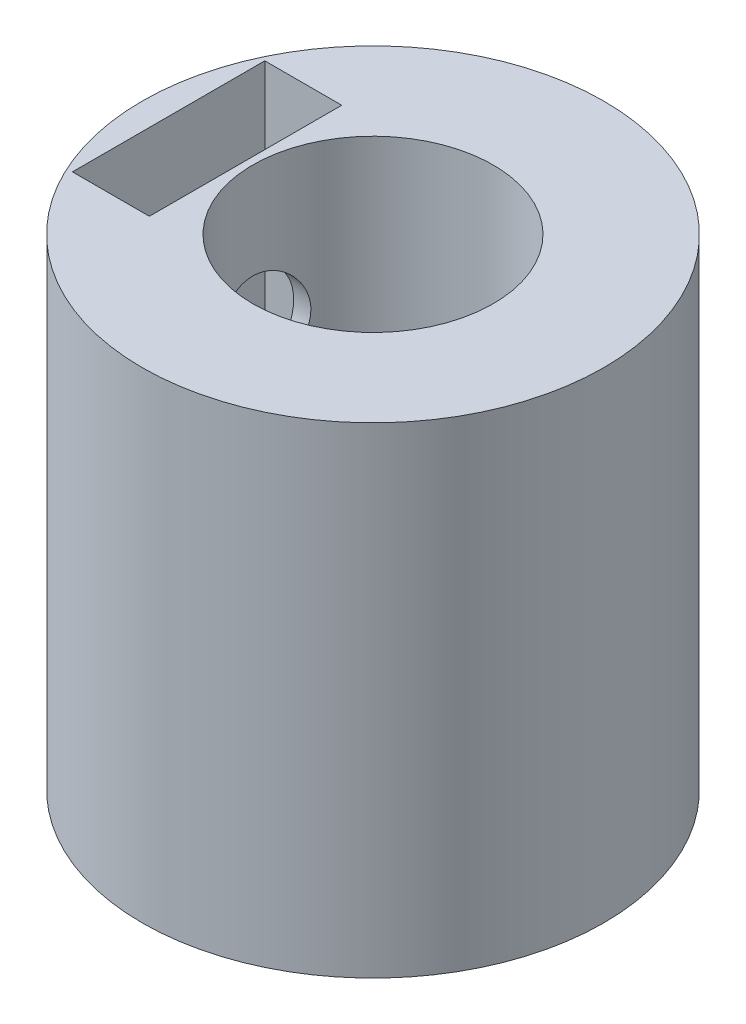
from build123d import *

# Parameters (mm, degrees)
IZIM1_R                     = 4.8
Y_KSEKLIK_EKSTR_ZYON1_DEPTH = 10
IZIM2_R                     = 2.5
KES_EKSTR_ZYON1_DEPTH       = 7
IZIM3_R                     = 1
KES_EKSTR_ZYON2_DEPTH       = 5.8
IZIM4_W                     = 1.6
IZIM4_H                     = 4
KES_EKSTR_ZYON3_DEPTH       = 5


with BuildPart() as part:
    # Çizim1 → Yükseklik-Ekstrüzyon1 (new body)
    with BuildSketch(Plane(origin=(0, 0, 0), x_dir=(1, 0, 0), z_dir=(0, 1, 0))):
        Circle(IZIM1_R)
    extrude(amount=Y_KSEKLIK_EKSTR_ZYON1_DEPTH)

    # Çizim2 → Kes-Ekstrüzyon1 (cut)
    with BuildSketch(Plane(origin=(0, 10, 0), x_dir=(1, 0, 0), z_dir=(0, 1, 0))):
        Circle(IZIM2_R)
    extrude(amount=-KES_EKSTR_ZYON1_DEPTH, mode=Mode.SUBTRACT)

    # Çizim3 → Kes-Ekstrüzyon2 (cut, through all)
    with BuildSketch(Plane(origin=(0, 0, 0), x_dir=(0, 0, -1), z_dir=(1, 0, 0))):
        with Locations((0, 7)):
            Circle(IZIM3_R)
    extrude(amount=-KES_EKSTR_ZYON2_DEPTH, mode=Mode.SUBTRACT)

    # Çizim4 → Kes-Ekstrüzyon3 (cut)
    with BuildSketch(Plane(origin=(0, 10, 0), x_dir=(1, 0, 0), z_dir=(0, 1, 0))):
        with Locations((-3.45, 0)):
            Rectangle(IZIM4_W, IZIM4_H)
    extrude(amount=-KES_EKSTR_ZYON3_DEPTH, mode=Mode.SUBTRACT)


solid = part.part
